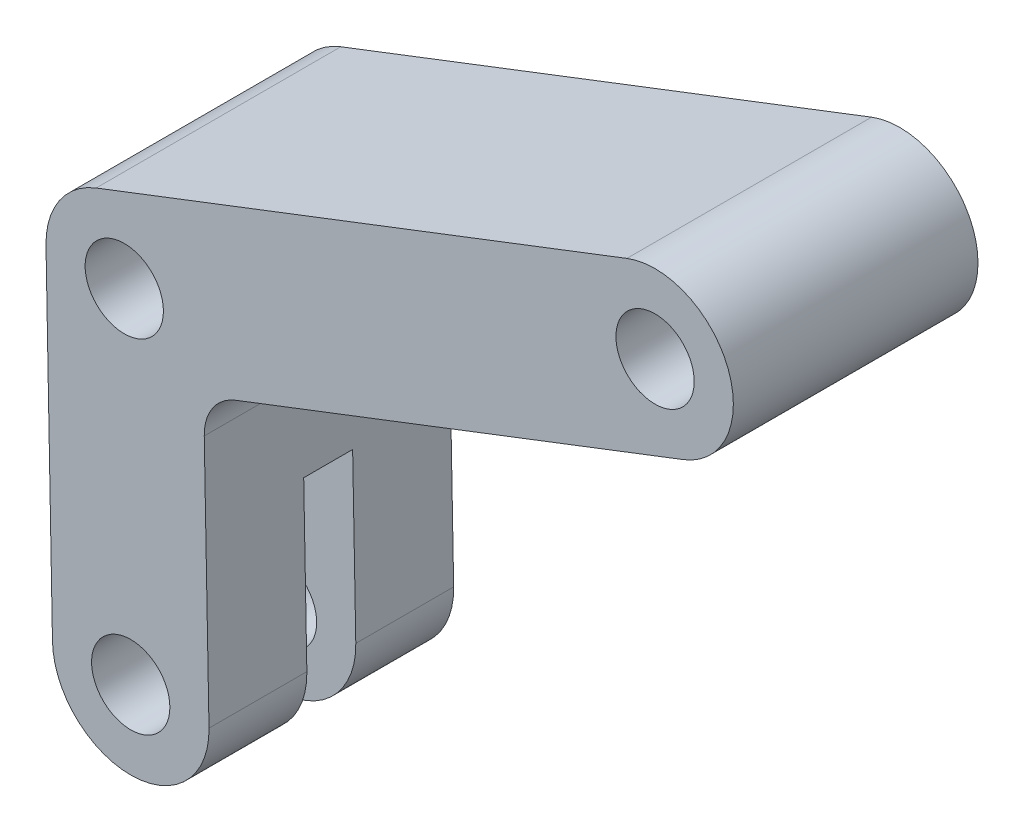
from build123d import *

# Parameters (mm, degrees)
SKETCH1_R               = 4
BOSS_EXTRUDE1_DEPTH     = 25
FILLET1_R               = 5
SKETCH2_W               = 5
SKETCH2_H               = 30
CUT_EXTRUDE1_DEPTH      = 1.812260823
CUT_EXTRUDE1_DEPTH_BACK = 71.77899263


with BuildPart() as part:
    # Sketch1 → Boss-Extrude1 (new body)
    with BuildSketch(Plane.XY):
        with BuildLine():
            ThreePointArc((56.45524489, 48.144548452), (61.045451548, 58.48524489), (50.70475511, 63.075451548))
            Line((50.70475511, 63.075451548), (-3.53524489, 42.185451548))
            ThreePointArc((-3.53524489, 42.185451548), (-7.298349786, 39.184561806), (-8.658548629, 34.567619439))
            Line((-8.658548629, 34.567619439), (-8, 0))
            ThreePointArc((-8, 0), (0.076026565, -7.999638739), (7.99855499, 0.152046264))
            Line((7.99855499, 0.152046264), (7.445069005, 29.268763528))
            Line((7.445069005, 29.268763528), (56.45524489, 48.144548452))
        make_face()
        Circle(SKETCH1_R, mode=Mode.SUBTRACT)
        with Locations((-0.66, 34.72)):
            Circle(SKETCH1_R, mode=Mode.SUBTRACT)
        with Locations((53.58, 55.61)):
            Circle(SKETCH1_R, mode=Mode.SUBTRACT)
    extrude(amount=-BOSS_EXTRUDE1_DEPTH)

    # Fillet1
    fillet1_edges = [part.edges().sort_by_distance(p)[0] for p in [
        (7.445069005, 29.268763528, -12.5),
    ]]
    fillet(fillet1_edges, radius=FILLET1_R)

    # Sketch2 → Cut-Extrude1 (cut, two sides)
    with BuildSketch(Plane(origin=(-7.997097521, -0.152352916, 0), x_dir=(0, 0, 1), z_dir=(-0.999818579, -0.01904757, 0))) as cut_extrude1_sk:
        with Locations((-12.5, 2)):
            Rectangle(SKETCH2_W, SKETCH2_H)
    extrude(amount=CUT_EXTRUDE1_DEPTH, mode=Mode.SUBTRACT)
    extrude(cut_extrude1_sk.sketch, amount=-CUT_EXTRUDE1_DEPTH_BACK, mode=Mode.SUBTRACT)


solid = part.part
